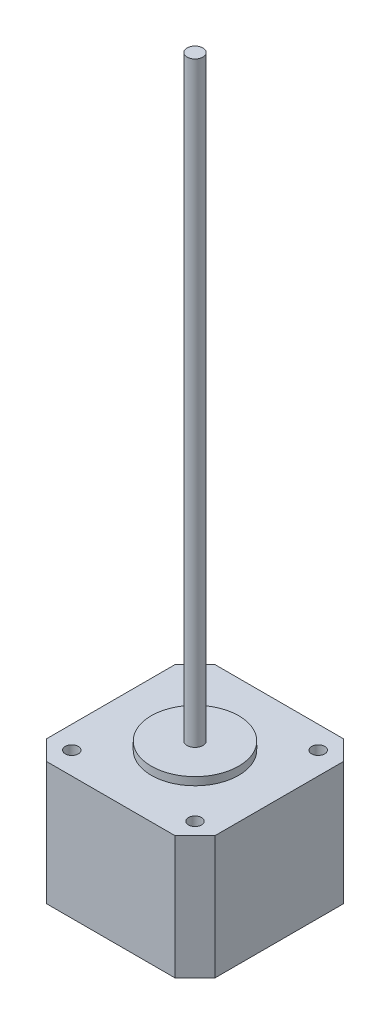
from build123d import *

# Parameters (mm, degrees)
SKETCH1_W           = 42.3
SKETCH1_H           = 42.3
BOSS_EXTRUDE1_DEPTH = 31
SKETCH2_R           = 1.644479294
CUT_EXTRUDE1_DEPTH  = 10
SKETCH3_R           = 11
BOSS_EXTRUDE2_DEPTH = 2
CHAMFER2_SIZE       = 5
SKETCH4_R           = 2
BOSS_EXTRUDE3_DEPTH = 150
SKETCH5_R           = 2.5
BOSS_EXTRUDE4_DEPTH = 13.5


with BuildPart() as part:
    # Sketch1 → Boss-Extrude1 (new body)
    with BuildSketch(Plane(origin=(0, 0, 0), x_dir=(1, 0, 0), z_dir=(0, 1, 0))):
        with Locations((21.15, 21.15)):
            Rectangle(SKETCH1_W, SKETCH1_H)
    extrude(amount=BOSS_EXTRUDE1_DEPTH)

    # Sketch2 → Cut-Extrude1 (cut)
    with BuildSketch(Plane(origin=(0, 31, 0), x_dir=(-1, 0, 0), z_dir=(0, 1, 0))):
        with Locations((-5.65, -36.65)):
            Circle(SKETCH2_R)
        with Locations((-36.65, -36.65)):
            Circle(SKETCH2_R)
        with Locations((-5.65, -5.65)):
            Circle(SKETCH2_R)
        with Locations((-36.65, -5.65)):
            Circle(SKETCH2_R)
    extrude(amount=-CUT_EXTRUDE1_DEPTH, mode=Mode.SUBTRACT)

    # Sketch3 → Boss-Extrude2 (add)
    with BuildSketch(Plane(origin=(0, 31, 0), x_dir=(-1, 0, 0), z_dir=(0, 1, 0))):
        with Locations((-21.15, -21.15)):
            Circle(SKETCH3_R)
    extrude(amount=BOSS_EXTRUDE2_DEPTH)

    # Chamfer2
    chamfer2_edges = [part.edges().sort_by_distance(p)[0] for p in [
        (0, 15.5, -42.3),
        (42.3, 15.5, -42.3),
        (42.3, 15.5, 0),
        (0, 15.5, 0),
    ]]
    chamfer(chamfer2_edges, length=CHAMFER2_SIZE)

    # Sketch4 → Boss-Extrude3 (add)
    with BuildSketch(Plane(origin=(0, 33, 0), x_dir=(-1, 0, 0), z_dir=(0, 1, 0))):
        with Locations((-21.15, -21.15)):
            Circle(SKETCH4_R)
    extrude(amount=BOSS_EXTRUDE3_DEPTH)

    # Sketch5 → Boss-Extrude4 (add)
    with BuildSketch(Plane.XZ):
        with Locations((21.15, -21.15)):
            Circle(SKETCH5_R)
    extrude(amount=BOSS_EXTRUDE4_DEPTH)


solid = part.part
